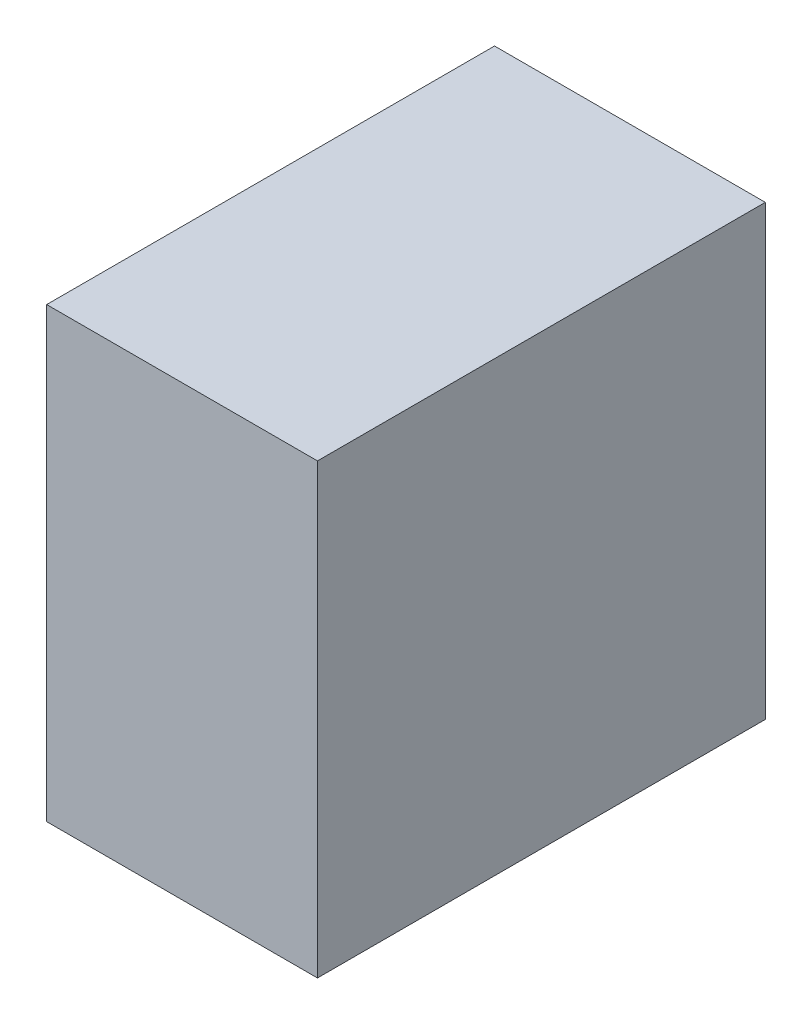
from build123d import *

# Parameters (mm, degrees)
SKETCH1_W           = 26
SKETCH1_H           = 43
BOSS_EXTRUDE1_DEPTH = 43


with BuildPart() as part:
    # Sketch1 → Boss-Extrude1 (new body)
    with BuildSketch(Plane.XY):
        Rectangle(SKETCH1_W, SKETCH1_H)
    extrude(amount=BOSS_EXTRUDE1_DEPTH)


solid = part.part
